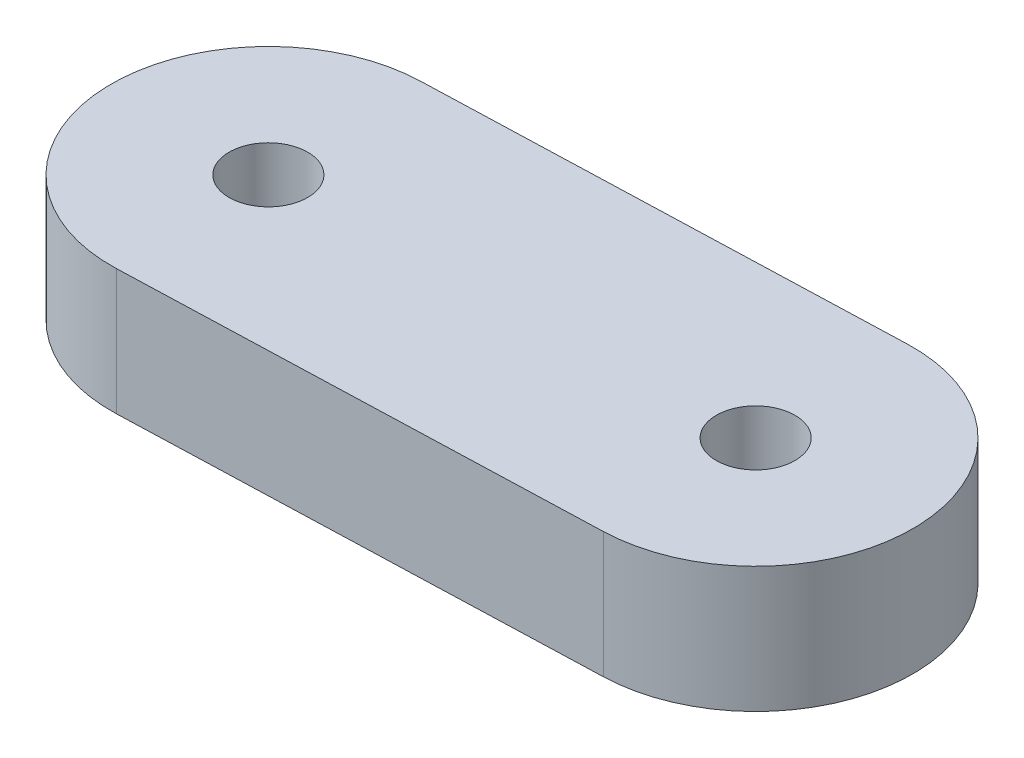
from build123d import *

# Parameters (mm, degrees)
BOSS_EXTRUDE1_DEPTH = 80
SKETCH2_R           = 25
CUT_EXTRUDE1_DEPTH  = 50
SKETCH3_R           = 25
CUT_EXTRUDE2_DEPTH  = 80


with BuildPart() as part:
    # Sketch1 → Boss-Extrude1 (new body)
    with BuildSketch(Plane(origin=(0, 0, 0), x_dir=(1, 0, 0), z_dir=(0, 1, 0))):
        with BuildLine():
            Line((3.346152766, -99.944000629), (-296.48584912, -109.982458927))
            ThreePointArc((-296.48584912, -109.982458927), (-399.776002515, -13.384611064), (-303.178154652, 89.905542331))
            Line((-303.178154652, 89.905542331), (-3.346152766, 99.944000629))
            ThreePointArc((-3.346152766, 99.944000629), (99.944000629, 3.346152766), (3.346152766, -99.944000629))
        make_face()
    extrude(amount=BOSS_EXTRUDE1_DEPTH)

    # Sketch2 → Cut-Extrude1 (cut)
    with BuildSketch(Plane(origin=(0, 80, 0), x_dir=(1, 0, 0), z_dir=(0, 1, 0))):
        Circle(SKETCH2_R)
    extrude(amount=-CUT_EXTRUDE1_DEPTH, mode=Mode.SUBTRACT)

    # Sketch3 → Cut-Extrude2 (cut)
    with BuildSketch(Plane(origin=(0, 80, 0), x_dir=(1, 0, 0), z_dir=(0, 1, 0))):
        with Locations((-299.832001886, -10.038458298)):
            Circle(SKETCH3_R)
    extrude(amount=-CUT_EXTRUDE2_DEPTH, mode=Mode.SUBTRACT)


solid = part.part
